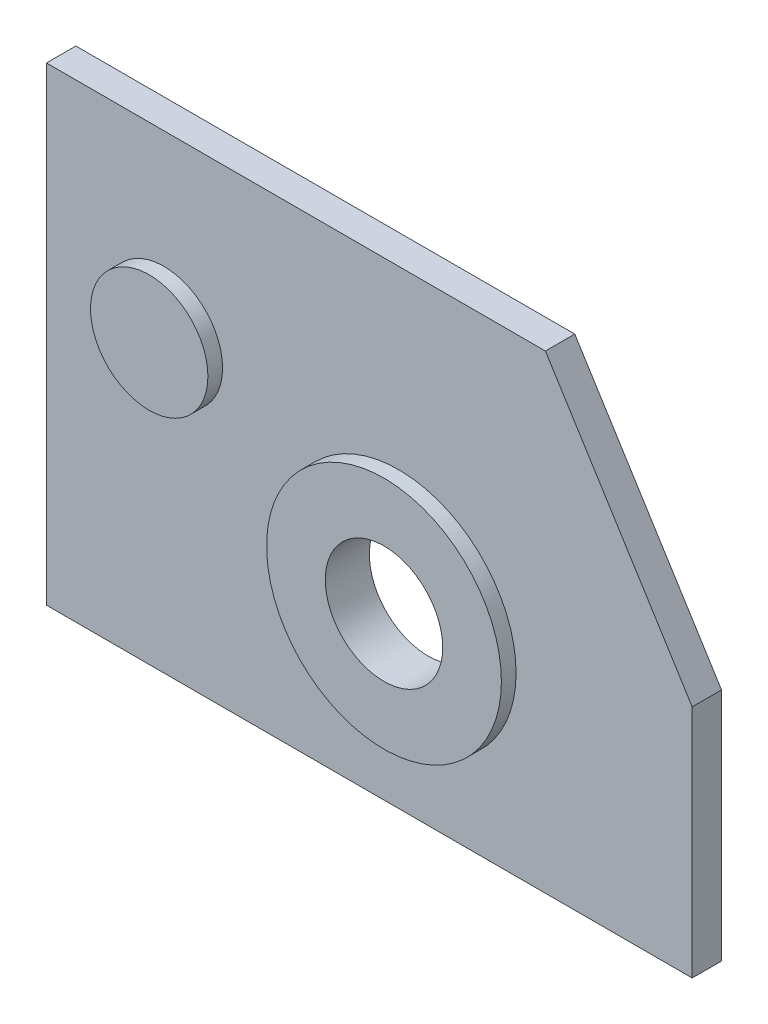
from build123d import *

# Parameters (mm, degrees)
BOSS_EXTRUDE2_DEPTH = 6.35
SKETCH2_R           = 12.7
SKETCH2_R_2         = 25.4
BOSS_EXTRUDE4_DEPTH = 3.175
SKETCH5_R           = 12.7
CUT_EXTRUDE1_DEPTH  = 127


with BuildPart() as part:
    # Sketch1 → Boss-Extrude2 (new body)
    with BuildSketch(Plane.XY):
        Polygon((0, 0), (139.7, 0), (139.7, 50.8), (107.95, 101.6), (0, 101.6), align=None)
    extrude(amount=BOSS_EXTRUDE2_DEPTH)

    # Sketch2 → Boss-Extrude4 (add)
    with BuildSketch(Plane.XY.offset(6.35)):
        with Locations((25.4, 63.5)):
            Circle(SKETCH2_R)
        with Locations((76.2, 38.1)):
            Circle(SKETCH2_R_2)
        with Locations((76.2, 38.1)):
            Circle(SKETCH2_R, mode=Mode.SUBTRACT)
    extrude(amount=BOSS_EXTRUDE4_DEPTH)

    # Sketch5 → Cut-Extrude1 (cut)
    with BuildSketch(Plane.XY.offset(6.35)):
        with Locations((76.2, 38.1)):
            Circle(SKETCH5_R)
    extrude(amount=-CUT_EXTRUDE1_DEPTH, mode=Mode.SUBTRACT)


solid = part.part
